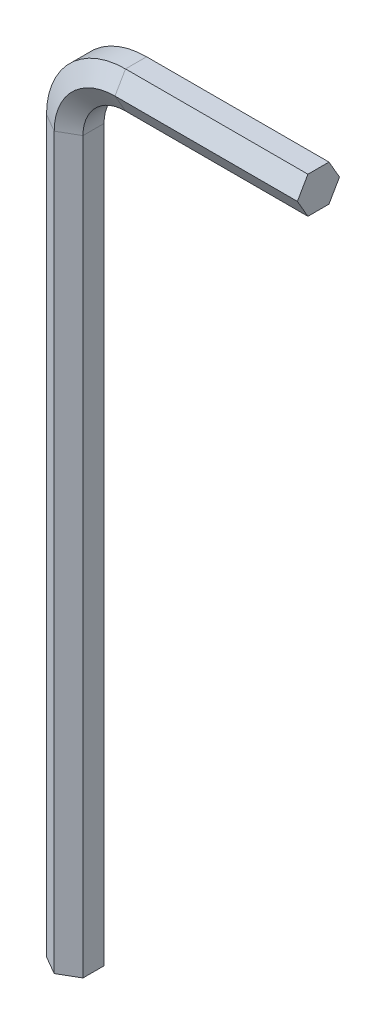
from build123d import *


with BuildPart() as part:
    # Táhnout po křivce1: sweep along a path in Skica1
    with BuildLine(Plane.XY) as t_hnout_po_k_ivce1_path:
        Line((0, 0), (0, 60))
        ThreePointArc((0, 60), (1.464466094, 63.535533906), (5, 65))
        Line((5, 65), (20, 65))
    # Skica2 → Táhnout po křivce1 (sweep)
    with BuildSketch(Plane(origin=(0, 0, 0), x_dir=(1, 0, 0), z_dir=(0, 1, 0))):
        Polygon((1.5, 0.866025404), (0, 1.732050808), (-1.5, 0.866025404), (-1.5, -0.866025404), (0, -1.732050808), (1.5, -0.866025404), align=None)
    sweep(path=t_hnout_po_k_ivce1_path.line)


solid = part.part
